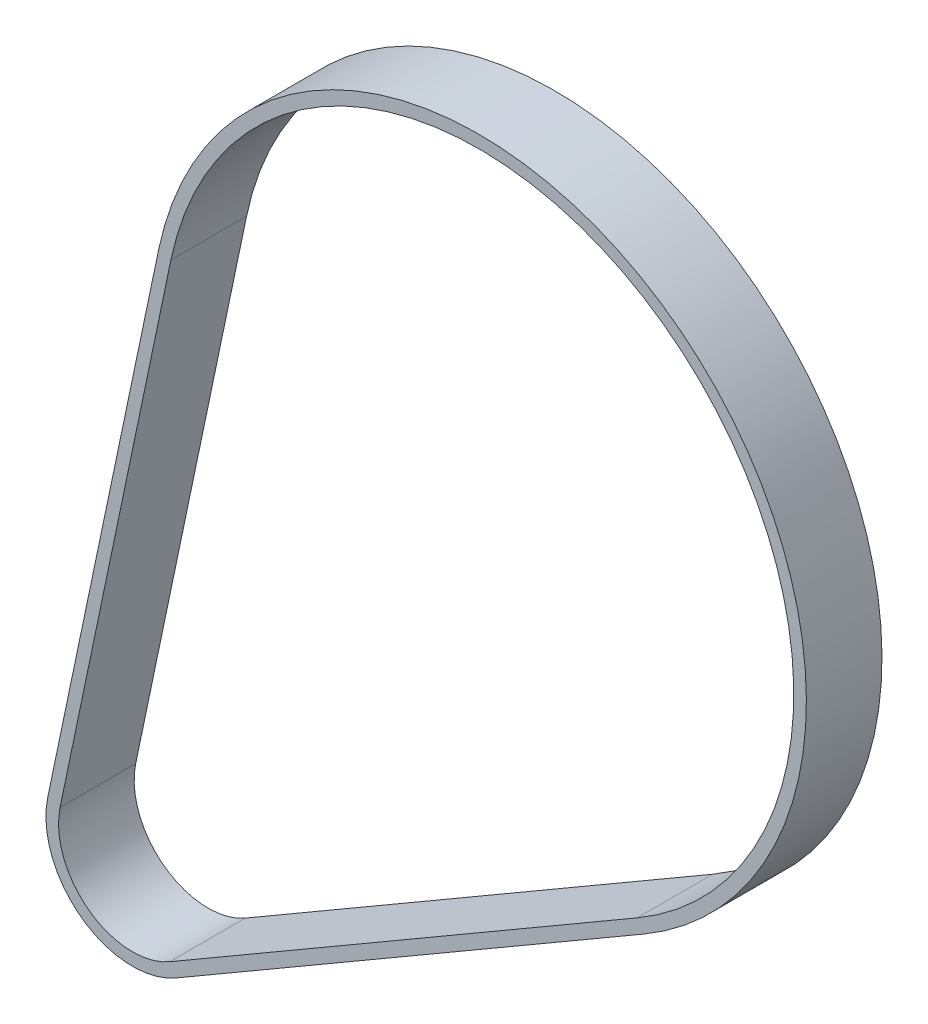
from build123d import *

# Parameters (mm, degrees)
EXTRUDE_THIN1_DEPTH      = 3
EXTRUDE_THIN1_DEPTH_BACK = 3


with BuildPart() as part:
    # Sketch2 → Extrude-Thin1 (new, two sides)
    with BuildSketch(Plane.XY) as extrude_thin1_sk:
        with BuildLine():
            Line((-42.218873031, 27.812367004), (-33.426518735, 69.811728506))
            ThreePointArc((-33.426518735, 69.811728506), (7.206095545, 85.551006884), (5.054820151, 42.029676007))
            Line((5.054820151, 42.029676007), (-32.043042704, 20.465807333))
            ThreePointArc((-32.043042704, 20.465807333), (-39.516230782, 20.835209769), (-42.218873031, 27.812367004))
        make_face()
        with BuildLine():
            Line((-41.240090772, 27.60746388), (-32.447736476, 69.606825381))
            ThreePointArc((-32.447736476, 69.606825381), (6.620743822, 84.740227406), (4.552280795, 42.894230341))
            Line((4.552280795, 42.894230341), (-32.54558206, 21.330361667))
            ThreePointArc((-32.54558206, 21.330361667), (-38.93087906, 21.645989246), (-41.240090772, 27.60746388))
        make_face(mode=Mode.SUBTRACT)
    extrude(amount=EXTRUDE_THIN1_DEPTH)
    extrude(extrude_thin1_sk.sketch, amount=-EXTRUDE_THIN1_DEPTH_BACK)


solid = part.part
